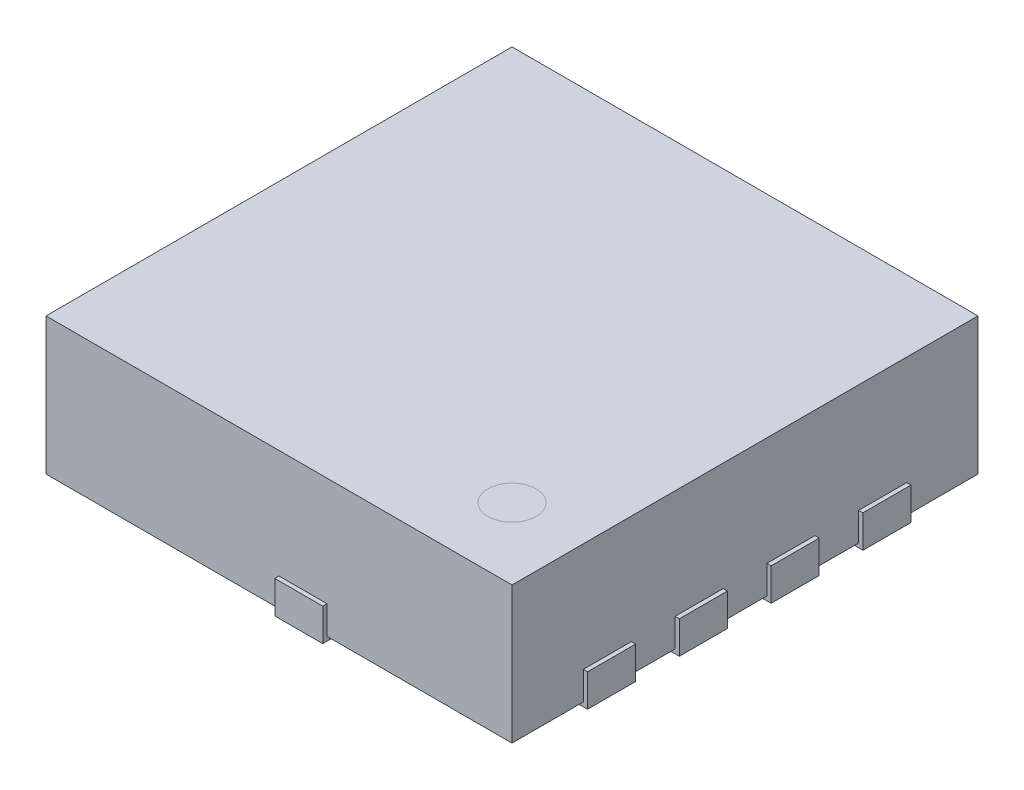
from build123d import *

# Parameters (mm, degrees)
EXTRUDE_START       = 0.03
SKETCH_1_W          = 3.3
SKETCH_1_H          = 3.3
EXTRUDE_1_DEPTH     = 0.97
SKETCH_2_W          = 0.48
SKETCH_2_H          = 0.34
EXTRUDE_2_DEPTH     = 0.23
EXTRUDE_2_2_DEPTH   = 0.23
EXTRUDE_2_3_DEPTH   = 0.23
EXTRUDE_2_4_DEPTH   = 0.23
EXTRUDE_3_DEPTH     = 0.23
CUT_EXTRUDE_START   = 1
SKETCH_4_R          = 0.17
CUT_EXTRUDE_1_DEPTH = 0.03
EXTRUDE_START_2     = 1
SKETCH_4_2_R        = 0.17
EXTRUDE_4_DEPTH     = 0.03


with BuildPart() as part:
    # Эскиз1 → Бобышка-Вытянуть1 (new body)
    with BuildSketch(Plane(origin=(0, 0, 0), x_dir=(1, 0, 0), z_dir=(0, 1, 0)).offset(EXTRUDE_START)):
        Rectangle(SKETCH_1_W, SKETCH_1_H)
    extrude(amount=EXTRUDE_1_DEPTH)

    # Эскиз4 → Вырез-Вытянуть1 (cut)
    with BuildSketch(Plane(origin=(0, 0, 0), x_dir=(1, 0, 0), z_dir=(0, 1, 0)).offset(CUT_EXTRUDE_START)):
        with Locations((1.145, -1.145)):
            Circle(SKETCH_4_R)
    extrude(amount=-CUT_EXTRUDE_1_DEPTH, mode=Mode.SUBTRACT)


with BuildPart() as body_2:
    # Эскиз2 → Бобышка-Вытянуть2 (new body)
    with BuildSketch(Plane(origin=(0, 0, 0), x_dir=(1, 0, 0), z_dir=(0, 1, 0))):
        with Locations((1.44, 0.975)):
            Rectangle(SKETCH_2_W, SKETCH_2_H)
    extrude(amount=EXTRUDE_2_DEPTH)


with BuildPart() as body_3:
    # Эскиз2 → Extrude 2 2 (new body)
    with BuildSketch(Plane(origin=(0, 0, 0), x_dir=(1, 0, 0), z_dir=(0, 1, 0))):
        with Locations((1.44, -0.975)):
            Rectangle(SKETCH_2_W, SKETCH_2_H)
    extrude(amount=EXTRUDE_2_2_DEPTH)


with BuildPart() as body_4:
    # Эскиз2 → Extrude 2 3 (new body)
    with BuildSketch(Plane(origin=(0, 0, 0), x_dir=(1, 0, 0), z_dir=(0, 1, 0))):
        with Locations((1.44, -0.325)):
            Rectangle(SKETCH_2_W, SKETCH_2_H)
    extrude(amount=EXTRUDE_2_3_DEPTH)


with BuildPart() as body_5:
    # Эскиз2 → Extrude 2 4 (new body)
    with BuildSketch(Plane(origin=(0, 0, 0), x_dir=(1, 0, 0), z_dir=(0, 1, 0))):
        with Locations((1.44, 0.325)):
            Rectangle(SKETCH_2_W, SKETCH_2_H)
    extrude(amount=EXTRUDE_2_4_DEPTH)


with BuildPart() as body_6:
    # Эскиз3 → Бобышка-Вытянуть3 (new body)
    with BuildSketch(Plane(origin=(0, 0, 0), x_dir=(1, 0, 0), z_dir=(0, 1, 0))):
        Polygon((-1.2, -1.145), (-1.2, -1.225), (0, -1.225), (0, -1.68), (0.34, -1.68), (0.34, -1.225), (0.55, -1.225), (0.55, 1.225), (0.34, 1.225), (0.34, 1.68), (0, 1.68), (0, 1.225), (-1.2, 1.225), (-1.2, 1.145), (-1.68, 1.145), (-1.68, 0.805), (-1.2, 0.805), (-1.2, 0.495), (-1.68, 0.495), (-1.68, 0.155), (-1.2, 0.155), (-1.2, -0.155), (-1.68, -0.155), (-1.68, -0.495), (-1.2, -0.495), (-1.2, -0.805), (-1.68, -0.805), (-1.68, -1.145), align=None)
    extrude(amount=EXTRUDE_3_DEPTH)


with BuildPart() as body_7:
    # Эскиз4<2> → Бобышка-Вытянуть4 (new body)
    with BuildSketch(Plane(origin=(0, 0, 0), x_dir=(1, 0, 0), z_dir=(0, 1, 0)).offset(EXTRUDE_START_2)):
        with Locations((1.145, -1.145)):
            Circle(SKETCH_4_2_R)
    extrude(amount=-EXTRUDE_4_DEPTH)


solid = Compound([part.part, body_2.part, body_3.part, body_4.part, body_5.part, body_6.part, body_7.part])
